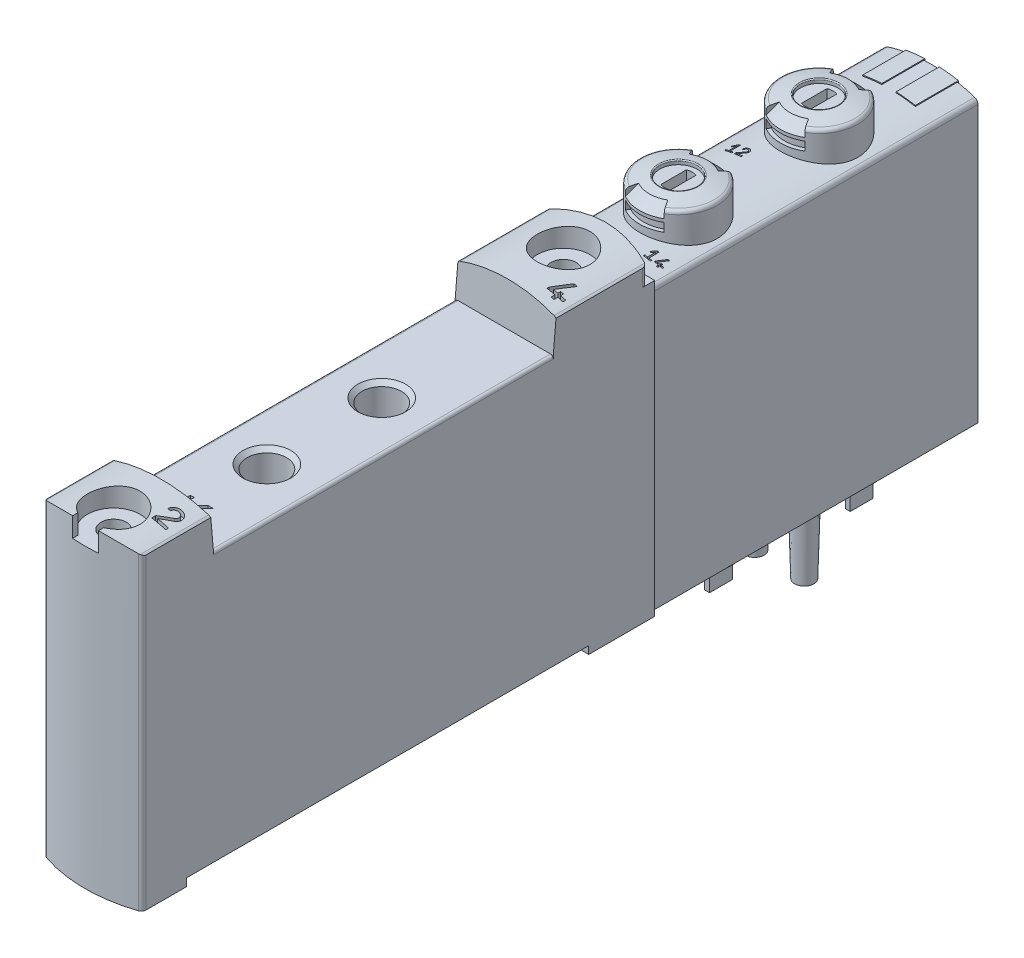
from build123d import *

# Parameters (mm, degrees)
BOSS_EXTRUDE1_DEPTH          = 34
SKETCH2_W                    = 34.1
SKETCH2_H                    = 0.4
CUT_EXTRUDE1_DEPTH           = 6
CUT_EXTRUDE1_DEPTH_BACK      = 6
CUT_EXTRUDE2_DEPTH           = 1.9
CUT_EXTRUDE3_DEPTH           = 1.9
SKETCH9_W                    = 0.5
SKETCH9_H                    = 2.4
BOSS_EXTRUDE2_DEPTH          = 2.5
SKETCH10_W                   = 0.5
SKETCH10_H                   = 2.4
BOSS_EXTRUDE3_DEPTH          = 2.5
SKETCH11_W                   = 0.5
SKETCH11_H                   = 2.4
BOSS_EXTRUDE4_DEPTH          = 2.5
SKETCH12_W                   = 0.5
SKETCH12_H                   = 2.4
BOSS_EXTRUDE5_DEPTH          = 2.5
CUT_REVOLVE1_ANGLE           = 30
CUT_REVOLVE1_OTHER_WAY_ANGLE = 30
CUT_REVOLVE2_ANGLE           = 30
CUT_REVOLVE2_OTHER_WAY_ANGLE = 30
CUT_EXTRUDE4_DEPTH           = 1.7
CUT_REVOLVE3_ANGLE           = 30
CUT_REVOLVE3_OTHER_WAY_ANGLE = 30
CUT_REVOLVE4_ANGLE           = 30
CUT_REVOLVE4_OTHER_WAY_ANGLE = 30
CUT_EXTRUDE5_DEPTH           = 1.7
BOSS_EXTRUDE6_DEPTH          = 4.5
BOSS_EXTRUDE7_DEPTH          = 4.5
BOSS_EXTRUDE8_DEPTH          = 33.1
CUT_EXTRUDE6_DEPTH           = 10
CUT_EXTRUDE6_DEPTH_BACK      = 10
CUT_EXTRUDE7_DEPTH           = 10
SKETCH26_W                   = 42
SKETCH26_H                   = 1
CUT_EXTRUDE8_DEPTH           = 10
CUT_EXTRUDE8_DEPTH_BACK      = 10
CUT_EXTRUDE9_DEPTH           = 55
CUT_EXTRUDE10_DEPTH          = 35.5
CUT_EXTRUDE11_DEPTH          = 2.1
CUT_EXTRUDE11_DEPTH_BACK     = 2.1
SKETCH30_W                   = 1.325
SKETCH30_H                   = 31
CUT_EXTRUDE12_DEPTH          = 3.5
CUT_EXTRUDE12_DEPTH_BACK     = 3.5
CUT_EXTRUDE13_DEPTH          = 3.5
CUT_EXTRUDE13_DEPTH_BACK     = 3.5
CUT_EXTRUDE14_DEPTH          = 3.5
CUT_EXTRUDE14_DEPTH_BACK     = 3.5
CUT_EXTRUDE15_DEPTH          = 3.5
CUT_EXTRUDE15_DEPTH_BACK     = 3.5
CUT_EXTRUDE16_DEPTH          = 1
CUT_EXTRUDE16_DEPTH_BACK     = 1
CUT_EXTRUDE17_DEPTH          = 1
CUT_EXTRUDE17_DEPTH_BACK     = 1
CUT_EXTRUDE18_DEPTH          = 4.5
CUT_EXTRUDE18_DEPTH_BACK     = 4.5


with BuildPart() as part:
    # Sketch1 → Boss-Extrude1 (new body)
    with BuildSketch(Plane.XY.offset(-23.2)):
        with BuildLine():
            Line((-4.9, 29.216294728), (-4.9, 0))
            Line((-4.9, 0), (4.9, 0))
            Line((4.9, 0), (4.9, 29.216294728))
            ThreePointArc((4.9, 29.216294728), (4.803647166, 29.511369236), (4.551724138, 29.692718684))
            ThreePointArc((4.551724138, 29.692718684), (0, 30.4), (-4.551724138, 29.692718684))
            ThreePointArc((-4.551724138, 29.692718684), (-4.803647166, 29.511369236), (-4.9, 29.216294728))
        make_face()
    extrude(amount=BOSS_EXTRUDE1_DEPTH)

    # Sketch2 → Cut-Extrude1 (cut, two sides)
    with BuildSketch(Plane(origin=(0, 0, 0), x_dir=(0, 0, -1), z_dir=(1, 0, 0))) as cut_extrude1_sk:
        with Locations((6.17, 0.2)):
            Rectangle(SKETCH2_W, SKETCH2_H)
    extrude(amount=CUT_EXTRUDE1_DEPTH, mode=Mode.SUBTRACT)
    extrude(cut_extrude1_sk.sketch, amount=-CUT_EXTRUDE1_DEPTH_BACK, mode=Mode.SUBTRACT)

    # Sketch3 → Cut-Extrude2 (cut)
    with BuildSketch(Plane(origin=(0, 0, 0), x_dir=(1, 0, 0), z_dir=(0, 1, 0))):
        with BuildLine():
            Line((-3.15, 2.465258607), (-3.15, -2.465258607))
            ThreePointArc((-3.15, -2.465258607), (0, -4), (3.15, -2.465258607))
            Line((3.15, -2.465258607), (3.15, 2.465258607))
            ThreePointArc((3.15, 2.465258607), (0, 4), (-3.15, 2.465258607))
        make_face()
    extrude(amount=CUT_EXTRUDE2_DEPTH, mode=Mode.SUBTRACT)

    # Sketch4 → Cut-Extrude3 (cut)
    with BuildSketch(Plane(origin=(0, 0, 0), x_dir=(1, 0, 0), z_dir=(0, 1, 0))):
        with BuildLine():
            Line((-3.15, 17.165258607), (-3.15, 12.234741393))
            ThreePointArc((-3.15, 12.234741393), (0, 10.7), (3.15, 12.234741393))
            Line((3.15, 12.234741393), (3.15, 17.165258607))
            ThreePointArc((3.15, 17.165258607), (0, 18.7), (-3.15, 17.165258607))
        make_face()
    extrude(amount=CUT_EXTRUDE3_DEPTH, mode=Mode.SUBTRACT)

    # Sketch5 → Revolve1 (revolve)
    with BuildSketch(Plane(origin=(0, 0, 0), x_dir=(0, 0, -1), z_dir=(1, 0, 0))):
        Polygon((0, 2.1), (3.05, 2.1), (3.05, 1.1), (2.25, 1.1), (2.25, -1.4), (2.65, -1.4), (2.65, -1.72), (2.430606898, -2.1), (0, -2.1), align=None)
    revolve(axis=Axis((0, -2.1, 0), (0, 1, 0)))

    # Sketch6 → Revolve2 (revolve)
    with BuildSketch(Plane(origin=(0, 0, 0), x_dir=(0, 0, -1), z_dir=(1, 0, 0))):
        Polygon((14.7, 2.1), (17.75, 2.1), (17.75, 1.1), (16.95, 1.1), (16.95, -1.4), (17.35, -1.4), (17.35, -1.72), (17.130606898, -2.1), (14.7, -2.1), align=None)
    revolve(axis=Axis((0, -2.1, -14.7), (0, 1, 0)))

    # Sketch7 → Revolve3 (revolve)
    with BuildSketch(Plane.XY.offset(-7.35)):
        with BuildLine():
            Line((2.6, 0.4), (3.8, 0.4))
            Line((3.8, 0.4), (3.6, -6.9))
            ThreePointArc((3.6, -6.9), (3.106540729, -7.021444616), (2.6, -7.06227766))
            Line((2.6, -7.06227766), (2.6, 0.4))
        make_face()
    revolve(axis=Axis((2.6, -7.06227766, -7.35), (0, 1, 0)))

    # Sketch8 → Revolve4 (revolve)
    with BuildSketch(Plane.XY.offset(-7.35)):
        with BuildLine():
            Line((-2.6, 0.4), (-1.4, 0.4))
            Line((-1.4, 0.4), (-1.6, -6.9))
            ThreePointArc((-1.6, -6.9), (-2.093459271, -7.021444616), (-2.6, -7.06227766))
            Line((-2.6, -7.06227766), (-2.6, 0.4))
        make_face()
    revolve(axis=Axis((-2.6, -7.06227766, -7.35), (0, 1, 0)))

    # Sketch9 → Boss-Extrude2 (add)
    with BuildSketch(Plane(origin=(0, -2.1, 0), x_dir=(-1, 0, 0), z_dir=(0, -1, 0))):
        with Locations((-1, 0)):
            Rectangle(SKETCH9_W, SKETCH9_H)
    extrude(amount=BOSS_EXTRUDE2_DEPTH)

    # Sketch10 → Boss-Extrude3 (add)
    with BuildSketch(Plane(origin=(0, -2.1, 0), x_dir=(-1, 0, 0), z_dir=(0, -1, 0))):
        with Locations((1, 0)):
            Rectangle(SKETCH10_W, SKETCH10_H)
    extrude(amount=BOSS_EXTRUDE3_DEPTH)

    # Sketch11 → Boss-Extrude4 (add)
    with BuildSketch(Plane(origin=(0, -2.1, 0), x_dir=(-1, 0, 0), z_dir=(0, -1, 0))):
        with Locations((-1, 14.7)):
            Rectangle(SKETCH11_W, SKETCH11_H)
    extrude(amount=BOSS_EXTRUDE4_DEPTH)

    # Sketch12 → Boss-Extrude5 (add)
    with BuildSketch(Plane(origin=(0, -2.1, 0), x_dir=(-1, 0, 0), z_dir=(0, -1, 0))):
        with Locations((1, 14.7)):
            Rectangle(SKETCH12_W, SKETCH12_H)
    extrude(amount=BOSS_EXTRUDE5_DEPTH)

    # Sketch13 → Revolve5 (revolve)
    with BuildSketch(Plane(origin=(0, 0, 0), x_dir=(0, 0, -1), z_dir=(1, 0, 0))):
        with BuildLine():
            Line((-3.2, 33.13), (-1.25, 33.13))
            Line((-1.25, 33.13), (-1.25, 33.458302748))
            ThreePointArc((-1.25, 33.458302748), (-1.215666434, 33.533721045), (-1.136241611, 33.55735176))
            ThreePointArc((-1.136241611, 33.55735176), (-0.28833743, 33.414694053), (0.549999769, 33.223687608))
            ThreePointArc((0.549999769, 33.223687608), (0.766227693, 33.081338282), (0.85, 32.836389214))
            Line((0.85, 32.836389214), (0.85, 28.4))
            Line((0.85, 28.4), (-3.2, 28.4))
            Line((-3.2, 28.4), (-3.2, 33.13))
        make_face()
    revolve(axis=Axis((0, 28.4, 3.2), (0, 1, 0)))

    # Sketch14 → Revolve6 (revolve)
    with BuildSketch(Plane(origin=(0, 0, 0), x_dir=(0, 0, -1), z_dir=(1, 0, 0))):
        with BuildLine():
            Line((11.5, 33.13), (13.45, 33.13))
            Line((13.45, 33.13), (13.45, 33.458302748))
            ThreePointArc((13.45, 33.458302748), (13.484333566, 33.533721045), (13.563758389, 33.55735176))
            ThreePointArc((13.563758389, 33.55735176), (14.411662804, 33.414694007), (15.250000231, 33.223687489))
            ThreePointArc((15.250000231, 33.223687489), (15.466227839, 33.081338094), (15.55, 32.836389214))
            Line((15.55, 32.836389214), (15.55, 28.4))
            Line((15.55, 28.4), (11.5, 28.4))
            Line((11.5, 28.4), (11.5, 33.13))
        make_face()
    revolve(axis=Axis((0, 28.4, -11.5), (0, 1, 0)))

    # Sketch15 → Cut-Revolve1 (revolve, cut)
    with BuildSketch(Plane(origin=(0, 0, 0), x_dir=(0, 0, -1), z_dir=(1, 0, 0))):
        Polygon((-0.47, 33.7), (0.9, 32.33), (0.9, 32.05), (0.45, 32.05), (0.45, 31.15), (0.9, 31.15), (0.9, 30.5), (1.3, 30.5), (1.3, 33.7), align=None)
    revolve(axis=Axis((0, 30.5, 3.2), (0, 1, 0)), revolution_arc=CUT_REVOLVE1_ANGLE, mode=Mode.SUBTRACT)

    # Sketch15 → Cut-Revolve1 other way (revolve, cut)
    with BuildSketch(Plane(origin=(0, 0, 0), x_dir=(0, 0, -1), z_dir=(1, 0, 0))):
        Polygon((-0.47, 33.7), (0.9, 32.33), (0.9, 32.05), (0.45, 32.05), (0.45, 31.15), (0.9, 31.15), (0.9, 30.5), (1.3, 30.5), (1.3, 33.7), align=None)
    revolve(axis=Axis((0, 30.5, 3.2), (0, -1, 0)), revolution_arc=CUT_REVOLVE1_OTHER_WAY_ANGLE, mode=Mode.SUBTRACT)

    # Sketch16 → Cut-Revolve2 (revolve, cut)
    with BuildSketch(Plane(origin=(0, 0, 0), x_dir=(0, 0, -1), z_dir=(1, 0, 0))):
        Polygon((-7.7, 30.5), (-7.3, 30.5), (-7.3, 31.15), (-6.85, 31.15), (-6.85, 32.05), (-7.3, 32.05), (-7.3, 32.33), (-5.93, 33.7), (-7.7, 33.7), align=None)
    revolve(axis=Axis((0, 33.7, 3.2), (0, -1, 0)), revolution_arc=CUT_REVOLVE2_ANGLE, mode=Mode.SUBTRACT)

    # Sketch16 → Cut-Revolve2 other way (revolve, cut)
    with BuildSketch(Plane(origin=(0, 0, 0), x_dir=(0, 0, -1), z_dir=(1, 0, 0))):
        Polygon((-7.7, 30.5), (-7.3, 30.5), (-7.3, 31.15), (-6.85, 31.15), (-6.85, 32.05), (-7.3, 32.05), (-7.3, 32.33), (-5.93, 33.7), (-7.7, 33.7), align=None)
    revolve(axis=Axis((0, 33.7, 3.2), (0, 1, 0)), revolution_arc=CUT_REVOLVE2_OTHER_WAY_ANGLE, mode=Mode.SUBTRACT)

    # Sketch17 → Cut-Extrude4 (cut)
    with BuildSketch(Plane(origin=(0, 33.13, 0), x_dir=(1, 0, 0), z_dir=(0, 1, 0))):
        with BuildLine():
            Line((0.5, -4.534400615), (0.5, -1.865599385))
            ThreePointArc((0.5, -1.865599385), (0, -1.775), (-0.5, -1.865599385))
            Line((-0.5, -1.865599385), (-0.5, -4.534400615))
            ThreePointArc((-0.5, -4.534400615), (0, -4.625), (0.5, -4.534400615))
        make_face()
    extrude(amount=-CUT_EXTRUDE4_DEPTH, mode=Mode.SUBTRACT)

    # Sketch18 → Cut-Revolve3 (revolve, cut)
    with BuildSketch(Plane(origin=(0, 0, 0), x_dir=(0, 0, -1), z_dir=(1, 0, 0))):
        Polygon((14.23, 33.7), (15.6, 32.33), (15.6, 32.05), (15.15, 32.05), (15.15, 31.15), (15.6, 31.15), (15.6, 30.5), (16, 30.5), (16, 33.7), align=None)
    revolve(axis=Axis((0, 30.5, -11.5), (0, 1, 0)), revolution_arc=CUT_REVOLVE3_ANGLE, mode=Mode.SUBTRACT)

    # Sketch18 → Cut-Revolve3 other way (revolve, cut)
    with BuildSketch(Plane(origin=(0, 0, 0), x_dir=(0, 0, -1), z_dir=(1, 0, 0))):
        Polygon((14.23, 33.7), (15.6, 32.33), (15.6, 32.05), (15.15, 32.05), (15.15, 31.15), (15.6, 31.15), (15.6, 30.5), (16, 30.5), (16, 33.7), align=None)
    revolve(axis=Axis((0, 30.5, -11.5), (0, -1, 0)), revolution_arc=CUT_REVOLVE3_OTHER_WAY_ANGLE, mode=Mode.SUBTRACT)

    # Sketch19 → Cut-Revolve4 (revolve, cut)
    with BuildSketch(Plane(origin=(0, 0, 0), x_dir=(0, 0, -1), z_dir=(1, 0, 0))):
        Polygon((7, 30.5), (7.4, 30.5), (7.4, 31.15), (7.85, 31.15), (7.85, 32.05), (7.4, 32.05), (7.4, 32.33), (8.77, 33.7), (7, 33.7), align=None)
    revolve(axis=Axis((0, 33.7, -11.5), (0, -1, 0)), revolution_arc=CUT_REVOLVE4_ANGLE, mode=Mode.SUBTRACT)

    # Sketch19 → Cut-Revolve4 other way (revolve, cut)
    with BuildSketch(Plane(origin=(0, 0, 0), x_dir=(0, 0, -1), z_dir=(1, 0, 0))):
        Polygon((7, 30.5), (7.4, 30.5), (7.4, 31.15), (7.85, 31.15), (7.85, 32.05), (7.4, 32.05), (7.4, 32.33), (8.77, 33.7), (7, 33.7), align=None)
    revolve(axis=Axis((0, 33.7, -11.5), (0, 1, 0)), revolution_arc=CUT_REVOLVE4_OTHER_WAY_ANGLE, mode=Mode.SUBTRACT)

    # Sketch20 → Cut-Extrude5 (cut)
    with BuildSketch(Plane(origin=(0, 33.13, 0), x_dir=(1, 0, 0), z_dir=(0, 1, 0))):
        with BuildLine():
            Line((0.5, 10.165599385), (0.5, 12.834400615))
            ThreePointArc((0.5, 12.834400615), (0, 12.925), (-0.5, 12.834400615))
            Line((-0.5, 12.834400615), (-0.5, 10.165599385))
            ThreePointArc((-0.5, 10.165599385), (0, 10.075), (0.5, 10.165599385))
        make_face()
    extrude(amount=-CUT_EXTRUDE5_DEPTH, mode=Mode.SUBTRACT)

    # Sketch21 → Boss-Extrude6 (add)
    with BuildSketch(Plane.XY.offset(-23.3)):
        with BuildLine():
            Line((0.75, 30.481362671), (0.75, 27))
            Line((0.75, 27), (2.75, 27))
            Line((2.75, 27), (2.75, 30.247474533))
            ThreePointArc((2.75, 30.247474533), (1.753903052, 30.397793974), (0.75, 30.481362671))
        make_face()
    extrude(amount=BOSS_EXTRUDE6_DEPTH)

    # Sketch22 → Boss-Extrude7 (add)
    with BuildSketch(Plane.XY.offset(-23.3)):
        with BuildLine():
            Line((-2.75, 30.247474533), (-2.75, 27))
            Line((-2.75, 27), (-0.75, 27))
            Line((-0.75, 27), (-0.75, 30.481362671))
            ThreePointArc((-0.75, 30.481362671), (-1.753903052, 30.397793974), (-2.75, 30.247474533))
        make_face()
    extrude(amount=BOSS_EXTRUDE7_DEPTH)

    # Sketch23 → Boss-Extrude8 (add)
    with BuildSketch(Plane(origin=(0, 0, 0), x_dir=(1, 0, 0), z_dir=(0, 1, 0))):
        with BuildLine():
            Line((5.125, -63.942611651), (5.125, -10.8))
            Line((5.125, -10.8), (-5.125, -10.8))
            Line((-5.125, -10.8), (-5.125, -63.942611651))
            ThreePointArc((-5.125, -63.942611651), (-5.031042719, -64.234380927), (-4.784482759, -64.416494812))
            ThreePointArc((-4.784482759, -64.416494812), (0, -65.2), (4.784482759, -64.416494812))
            ThreePointArc((4.784482759, -64.416494812), (5.031042719, -64.234380927), (5.125, -63.942611651))
        make_face()
    extrude(amount=BOSS_EXTRUDE8_DEPTH)

    # Sketch24 → Cut-Extrude6 (cut, two sides)
    with BuildSketch(Plane(origin=(0, 0, 0), x_dir=(0, 0, -1), z_dir=(1, 0, 0))) as cut_extrude6_sk:
        Polygon((-57.774886635, 38.9), (-56.9, 28.9), (-21.4, 28.9), (-20.525113365, 38.9), align=None)
    extrude(amount=CUT_EXTRUDE6_DEPTH, mode=Mode.SUBTRACT)
    extrude(cut_extrude6_sk.sketch, amount=-CUT_EXTRUDE6_DEPTH_BACK, mode=Mode.SUBTRACT)

    # Sketch25 → Cut-Extrude7 (cut)
    with BuildSketch(Plane(origin=(0, 30.4, 0), x_dir=(1, 0, 0), z_dir=(0, 1, 0))):
        with BuildLine():
            Line((-5.125, -8.8), (-5.125, -12.057388349))
            ThreePointArc((-5.125, -12.057388349), (-5.031042719, -11.765619073), (-4.784482759, -11.583505188))
            ThreePointArc((-4.784482759, -11.583505188), (0, -10.8), (4.784482759, -11.583505188))
            ThreePointArc((4.784482759, -11.583505188), (5.031042719, -11.765619073), (5.125, -12.057388349))
            Line((5.125, -12.057388349), (5.125, -8.8))
            Line((5.125, -8.8), (-5.125, -8.8))
        make_face()
    extrude(amount=CUT_EXTRUDE7_DEPTH, mode=Mode.SUBTRACT)

    # Sketch26 → Cut-Extrude8 (cut, two sides)
    with BuildSketch(Plane(origin=(0, 0, 0), x_dir=(0, 0, -1), z_dir=(1, 0, 0))) as cut_extrude8_sk:
        with Locations((-38.7, 0.3)):
            Rectangle(SKETCH26_W, SKETCH26_H)
    extrude(amount=CUT_EXTRUDE8_DEPTH, mode=Mode.SUBTRACT)
    extrude(cut_extrude8_sk.sketch, amount=-CUT_EXTRUDE8_DEPTH_BACK, mode=Mode.SUBTRACT)

    # Sketch27 → Cut-Extrude9 (cut)
    with BuildSketch(Plane.XY.offset(10.8)):
        with BuildLine():
            Line((-5.25, 35.1), (-5.25, 31.799908759))
            ThreePointArc((-5.25, 31.799908759), (-5.157367495, 32.089825513), (-4.913793103, 32.272319406))
            ThreePointArc((-4.913793103, 32.272319406), (0, 33.1), (4.913793103, 32.272319406))
            ThreePointArc((4.913793103, 32.272319406), (5.157367495, 32.089825513), (5.25, 31.799908759))
            Line((5.25, 31.799908759), (5.25, 35.1))
            Line((5.25, 35.1), (-5.25, 35.1))
        make_face()
    extrude(amount=CUT_EXTRUDE9_DEPTH, mode=Mode.SUBTRACT)

    # Sketch28 → Cut-Extrude10 (cut)
    with BuildSketch(Plane.XY.offset(21.4)):
        with BuildLine():
            Line((-4.825, 28.9), (4.825, 28.9))
            ThreePointArc((4.825, 28.9), (5.037132034, 28.812132034), (5.125, 28.6))
            Line((5.125, 28.6), (5.125, 33.6))
            Line((5.125, 33.6), (-5.125, 33.6))
            Line((-5.125, 33.6), (-5.125, 28.6))
            ThreePointArc((-5.125, 28.6), (-5.037132034, 28.812132034), (-4.825, 28.9))
        make_face()
    extrude(amount=CUT_EXTRUDE10_DEPTH, mode=Mode.SUBTRACT)

    # Sketch29 → Cut-Extrude11 (cut, two sides)
    with BuildSketch(Plane(origin=(0, 33.1, 0), x_dir=(1, 0, 0), z_dir=(0, 1, 0))) as cut_extrude11_sk:
        with BuildLine():
            Line((-1.35, -64.59582971), (-1.35, -66))
            Line((-1.35, -66), (1.35, -66))
            Line((1.35, -66), (1.35, -64.59582971))
            ThreePointArc((1.35, -64.59582971), (0, -59.45), (-1.35, -64.59582971))
        make_face()
    extrude(amount=CUT_EXTRUDE11_DEPTH, mode=Mode.SUBTRACT)
    extrude(cut_extrude11_sk.sketch, amount=-CUT_EXTRUDE11_DEPTH_BACK, mode=Mode.SUBTRACT)

    # Sketch30 → Cut-Revolve5 (revolve, cut)
    with BuildSketch(Plane(origin=(0, 0, 0), x_dir=(0, 0, -1), z_dir=(1, 0, 0))):
        with Locations((-61.5375, 15.5)):
            Rectangle(SKETCH30_W, SKETCH30_H)
    revolve(axis=Axis((0, 0, 62.2), (0, 1, 0)), mode=Mode.SUBTRACT)

    # Sketch31 → Cut-Revolve6 (revolve, cut)
    with BuildSketch(Plane(origin=(0, 0, 0), x_dir=(0, 0, -1), z_dir=(1, 0, 0))):
        Polygon((-15.2, 33.2), (-12.45, 33.2), (-12.45, 31), (-13.875, 31), (-13.875, 0), (-15.2, 0), align=None)
    revolve(axis=Axis((0, 0, 15.2), (0, 1, 0)), mode=Mode.SUBTRACT)

    # Sketch32 → Cut-Revolve7 (revolve, cut)
    with BuildSketch(Plane(origin=(0, 0, 0), x_dir=(0, 0, -1), z_dir=(1, 0, 0))):
        Polygon((-34.2, 28.9), (-31.7, 28.9), (-32.133, 28.467), (-32.133, 22.3), (-34.2, 22.3), align=None)
    revolve(axis=Axis((0, 22.3, 34.2), (0, 1, 0)), mode=Mode.SUBTRACT)

    # Sketch33 → Cut-Revolve8 (revolve, cut)
    with BuildSketch(Plane(origin=(0, 0, 0), x_dir=(0, 0, -1), z_dir=(1, 0, 0))):
        Polygon((-46.2, 28.9), (-43.7, 28.9), (-44.133, 28.467), (-44.133, 22.3), (-46.2, 22.3), align=None)
    revolve(axis=Axis((0, 22.3, 46.2), (0, 1, 0)), mode=Mode.SUBTRACT)

    # Sketch34 → Cut-Revolve9 (revolve, cut)
    with BuildSketch(Plane(origin=(0, 0, 0), x_dir=(0, 0, -1), z_dir=(1, 0, 0))):
        Polygon((-29.2, 7.3), (-27.1, 7.3), (-27.1, 2.8), (-26.2, 2.8), (-26.2, 1.3), (-25.7, 0.8), (-29.2, 0.8), align=None)
    revolve(axis=Axis((0, 0.8, 29.2), (0, 1, 0)), mode=Mode.SUBTRACT)

    # Sketch35 → Cut-Revolve10 (revolve, cut)
    with BuildSketch(Plane(origin=(0, 0, 0), x_dir=(0, 0, -1), z_dir=(1, 0, 0))):
        Polygon((-40.2, 7.3), (-38.1, 7.3), (-38.1, 2.8), (-37.2, 2.8), (-37.2, 1.3), (-36.7, 0.8), (-40.2, 0.8), align=None)
    revolve(axis=Axis((0, 0.8, 40.2), (0, 1, 0)), mode=Mode.SUBTRACT)

    # Sketch36 → Cut-Revolve11 (revolve, cut)
    with BuildSketch(Plane(origin=(0, 0, 0), x_dir=(0, 0, -1), z_dir=(1, 0, 0))):
        Polygon((-51.2, 7.3), (-49.1, 7.3), (-49.1, 2.8), (-48.2, 2.8), (-48.2, 1.3), (-47.7, 0.8), (-51.2, 0.8), align=None)
    revolve(axis=Axis((0, 0.8, 51.2), (0, 1, 0)), mode=Mode.SUBTRACT)

    # Sketch37 → Cut-Extrude12 (cut, two sides)
    with BuildSketch(Plane(origin=(0, 33.1, 0), x_dir=(1, 0, 0), z_dir=(0, 1, 0))) as cut_extrude12_sk:
        Polygon((-3.398476194, 5.738028118), (-3.297824684, 5.667551171), (-3.075, 5.985777799), (-3.075, 5.15), (-3.375, 5.15), (-3.375, 5), (-2.625, 5), (-2.625, 5.15), (-2.925, 5.15), (-2.925, 6.2), (-3.075, 6.2), align=None)
    extrude(amount=CUT_EXTRUDE12_DEPTH, mode=Mode.SUBTRACT)
    extrude(cut_extrude12_sk.sketch, amount=-CUT_EXTRUDE12_DEPTH_BACK, mode=Mode.SUBTRACT)

    # Sketch38 → Cut-Extrude13 (cut, two sides)
    with BuildSketch(Plane(origin=(0, 33.1, 0), x_dir=(1, 0, 0), z_dir=(0, 1, 0))) as cut_extrude13_sk:
        with BuildLine():
            Line((-2.3625, 5.8375), (-2.2125, 5.8375))
            ThreePointArc((-2.2125, 5.8375), (-1.915590111, 6.03251595), (-1.854559099, 5.682570356))
            Line((-1.854559099, 5.682570356), (-2.3625, 5.205738549))
            Line((-2.3625, 5.205738549), (-2.3625, 5))
            Line((-2.3625, 5), (-1.6375, 5))
            Line((-1.6375, 5), (-1.6375, 5.15))
            Line((-1.6375, 5.15), (-2.202713816, 5.15))
            Line((-2.202713816, 5.15), (-1.751894934, 5.573208255))
            ThreePointArc((-1.751894934, 5.573208255), (-1.85600666, 6.170174267), (-2.3625, 5.8375))
        make_face()
    extrude(amount=CUT_EXTRUDE13_DEPTH, mode=Mode.SUBTRACT)
    extrude(cut_extrude13_sk.sketch, amount=-CUT_EXTRUDE13_DEPTH_BACK, mode=Mode.SUBTRACT)

    # Sketch39 → Cut-Extrude14 (cut, two sides)
    with BuildSketch(Plane(origin=(0, 33.1, 0), x_dir=(1, 0, 0), z_dir=(0, 1, 0))) as cut_extrude14_sk:
        Polygon((2.101523806, -8.261971882), (2.202175316, -8.332448829), (2.425, -8.014222201), (2.425, -8.85), (2.125, -8.85), (2.125, -9), (2.875, -9), (2.875, -8.85), (2.575, -8.85), (2.575, -7.8), (2.425, -7.8), align=None)
    extrude(amount=CUT_EXTRUDE14_DEPTH, mode=Mode.SUBTRACT)
    extrude(cut_extrude14_sk.sketch, amount=-CUT_EXTRUDE14_DEPTH_BACK, mode=Mode.SUBTRACT)

    # Sketch40 → Cut-Extrude15 (cut, two sides)
    with BuildSketch(Plane(origin=(0, 33.1, 0), x_dir=(1, 0, 0), z_dir=(0, 1, 0))) as cut_extrude15_sk:
        Polygon((3.085, -8.8), (3.5, -8.8), (3.5, -9), (3.65, -9), (3.65, -8.8), (3.915, -8.8), (3.915, -8.65), (3.65, -8.65), (3.65, -8.5), (3.5, -8.5), (3.5, -8.65), (3.269946149, -8.65), (3.666307658, -7.8), (3.50080097, -7.8), (3.085, -8.691688058), align=None)
    extrude(amount=CUT_EXTRUDE15_DEPTH, mode=Mode.SUBTRACT)
    extrude(cut_extrude15_sk.sketch, amount=-CUT_EXTRUDE15_DEPTH_BACK, mode=Mode.SUBTRACT)

    # Sketch41 → Cut-Extrude16 (cut, two sides)
    with BuildSketch(Plane(origin=(0, 33.1, 0), x_dir=(1, 0, 0), z_dir=(0, 1, 0))) as cut_extrude16_sk:
        Polygon((2.67, -19.6), (3.5, -19.6), (3.5, -20), (3.8, -20), (3.8, -19.6), (4.33, -19.6), (4.33, -19.3), (3.8, -19.3), (3.8, -19), (3.5, -19), (3.5, -19.3), (3.039892297, -19.3), (3.832615316, -17.6), (3.501601941, -17.6), (2.67, -19.383376117), align=None)
    extrude(amount=CUT_EXTRUDE16_DEPTH, mode=Mode.SUBTRACT)
    extrude(cut_extrude16_sk.sketch, amount=-CUT_EXTRUDE16_DEPTH_BACK, mode=Mode.SUBTRACT)

    # Sketch42 → Cut-Extrude17 (cut, two sides)
    with BuildSketch(Plane(origin=(0, 33.1, 0), x_dir=(1, 0, 0), z_dir=(0, 1, 0))) as cut_extrude17_sk:
        with BuildLine():
            Line((2.775, -59.325), (3.075, -59.325))
            ThreePointArc((3.075, -59.325), (3.668819777, -58.9349681), (3.790881801, -59.634859287))
            Line((3.790881801, -59.634859287), (2.775, -60.588522903))
            Line((2.775, -60.588522903), (2.775, -61))
            Line((2.775, -61), (4.225, -61))
            Line((4.225, -61), (4.225, -60.7))
            Line((4.225, -60.7), (3.094572368, -60.7))
            Line((3.094572368, -60.7), (3.996210131, -59.85358349))
            ThreePointArc((3.996210131, -59.85358349), (3.787986679, -58.659651465), (2.775, -59.325))
        make_face()
    extrude(amount=CUT_EXTRUDE17_DEPTH, mode=Mode.SUBTRACT)
    extrude(cut_extrude17_sk.sketch, amount=-CUT_EXTRUDE17_DEPTH_BACK, mode=Mode.SUBTRACT)

    # Sketch43 → Cut-Extrude18 (cut, two sides)
    with BuildSketch(Plane(origin=(0, 33.1, 0), x_dir=(1, 0, 0), z_dir=(0, 1, 0))) as cut_extrude18_sk:
        Polygon((-1.2, -53), (-1.2, -56), (-0.78, -56), (-0.78, -54.95), (-0.327272727, -54.504132231), (0.66, -56), (1.2, -56), (0, -54.181818182), (1.2, -53), (0.66, -53), (-0.78, -54.418181818), (-0.78, -53), align=None)
    extrude(amount=CUT_EXTRUDE18_DEPTH, mode=Mode.SUBTRACT)
    extrude(cut_extrude18_sk.sketch, amount=-CUT_EXTRUDE18_DEPTH_BACK, mode=Mode.SUBTRACT)


solid = part.part
